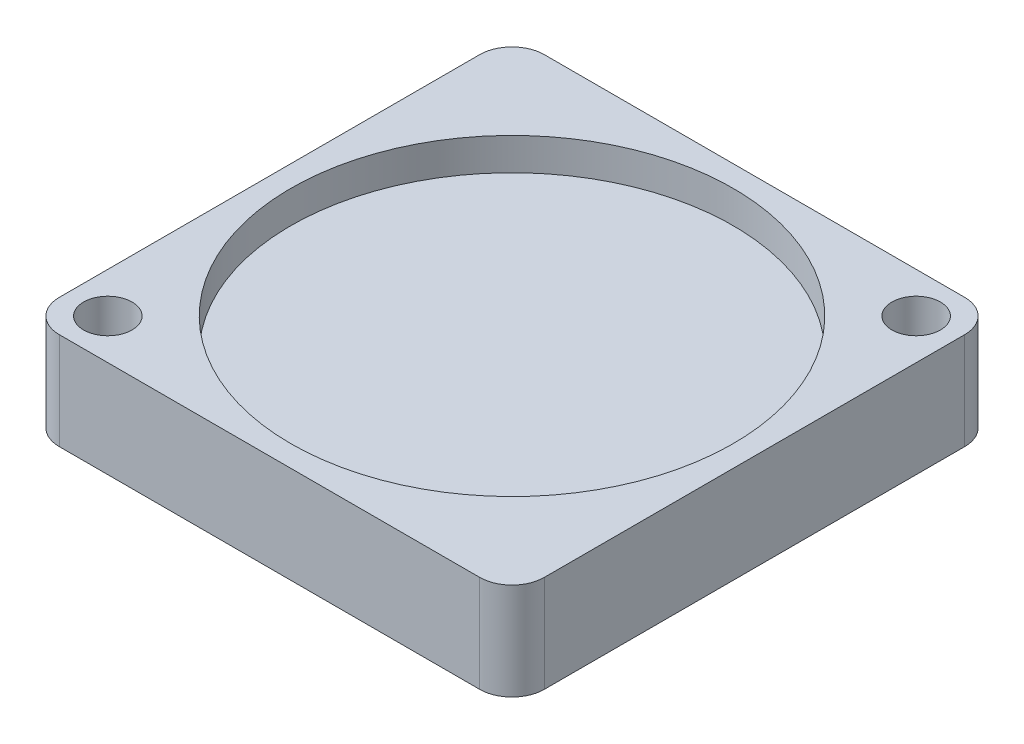
from build123d import *

# Parameters (mm, degrees)
SKETCH_1_W          = 15
SKETCH_1_H          = 15
EXTRUDE_1_DEPTH     = 3
FILLET_1_R          = 1
SKETCH_2_R          = 0.75
CUT_EXTRUDE_1_DEPTH = 4
SKETCH_3_R          = 6.839868167
CUT_EXTRUDE_2_DEPTH = 1


with BuildPart() as part:
    # 草图1 → 凸台-拉伸1 (new body)
    with BuildSketch(Plane(origin=(0, 0, 0), x_dir=(1, 0, 0), z_dir=(0, 1, 0))):
        Rectangle(SKETCH_1_W, SKETCH_1_H)
    extrude(amount=EXTRUDE_1_DEPTH)

    # 圆角1
    fillet_1_edges = [part.edges().sort_by_distance(p)[0] for p in [
        (-7.5, 1.5, -7.5),
        (7.5, 1.5, -7.5),
        (7.5, 1.5, 7.5),
        (-7.5, 1.5, 7.5),
    ]]
    fillet(fillet_1_edges, radius=FILLET_1_R)

    # 草图2 → 切除-拉伸1 (cut, through all)
    with BuildSketch(Plane(origin=(0, 3, 0), x_dir=(1, 0, 0), z_dir=(0, 1, 0))):
        with Locations((-6.25, -6.25)):
            Circle(SKETCH_2_R)
        with Locations((6.25, 6.25)):
            Circle(SKETCH_2_R)
    extrude(amount=-CUT_EXTRUDE_1_DEPTH, mode=Mode.SUBTRACT)

    # 草图3 → 切除-拉伸2 (cut)
    with BuildSketch(Plane(origin=(0, 3, 0), x_dir=(1, 0, 0), z_dir=(0, 1, 0))):
        Circle(SKETCH_3_R)
    extrude(amount=-CUT_EXTRUDE_2_DEPTH, mode=Mode.SUBTRACT)


solid = part.part
